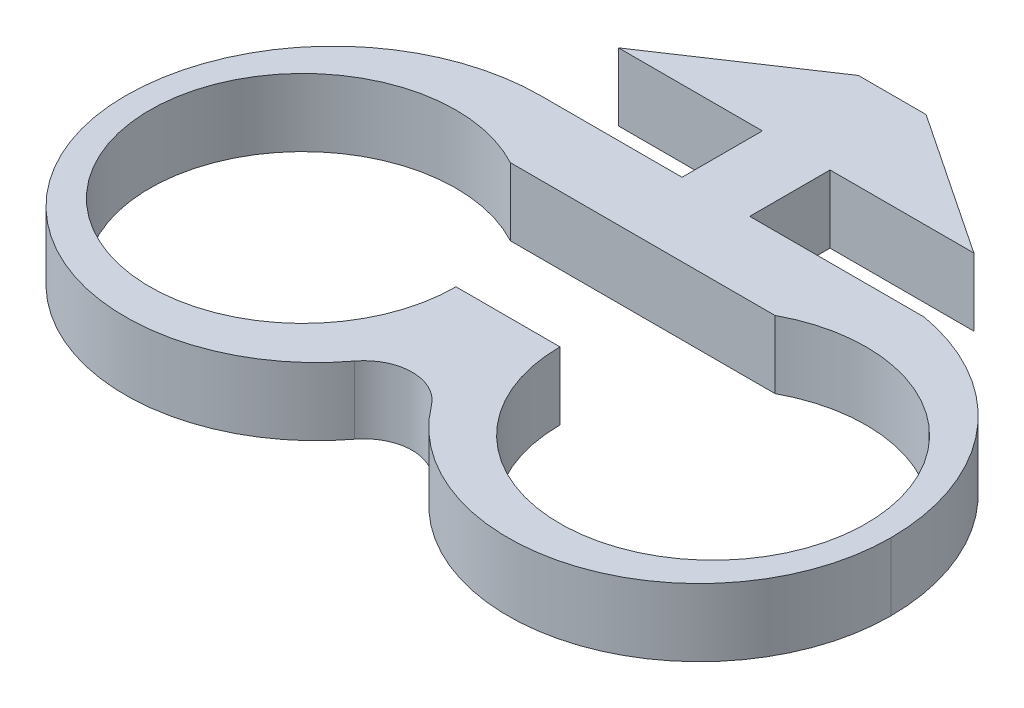
from build123d import *

# Parameters (mm, degrees)
BOSS_EXTRUDE1_DEPTH = 3.5814
BOSS_EXTRUDE2_DEPTH = 3.5814
SKETCH4_R           = 8.1
CUT_EXTRUDE2_DEPTH  = 4.5814
CUT_EXTRUDE4_REACH  = 5.581
CUT_EXTRUDE5_REACH  = 5.581


with BuildPart() as part:
    # Sketch1 → Boss-Extrude1 (new body)
    with BuildSketch(Plane(origin=(0, 0, 0), x_dir=(1, 0, 0), z_dir=(0, 1, 0))):
        Polygon((-20.25, -13.1232), (20.25, -13.1232), (20.25, -2.125), (1.7907, -2.125), (1.7907, 2.125), (9.398, 2.125), (1.7907, 7.205), (-1.7907, 7.205), (-9.398, 2.125), (-1.7907, 2.125), (-1.7907, -2.125), (-20.25, -2.125), align=None)
    extrude(amount=BOSS_EXTRUDE1_DEPTH)

    # Sketch3 → Boss-Extrude2 (add)
    with BuildSketch(Plane(origin=(0, 3.5814, 0), x_dir=(1, 0, 0), z_dir=(0, 1, 0))):
        Polygon((-20.25, -2.125), (-20.25, -13.1232), (20.25, -13.1232), (20.25, -2.125), (1.7907, -2.125), (1.7907, 2.125), (9.398, 2.125), (1.7907, 7.205), (-1.7907, 7.205), (-9.398, 2.125), (-1.7907, 2.125), (-1.7907, -2.125), align=None)
        with BuildLine():
            Line((20.25, -13.1232), (-20.25, -13.1232))
            ThreePointArc((-20.25, -13.1232), (-13.331227209, -22.72714357), (-2.030596131, -19.205654357))
            ThreePointArc((-2.030596131, -19.205654357), (0, -18.191524388), (2.030596131, -19.205654357))
            ThreePointArc((2.030596131, -19.205654357), (13.331227209, -22.72714357), (20.25, -13.1232))
        make_face()
    extrude(amount=-BOSS_EXTRUDE2_DEPTH)

    # Sketch4 → Cut-Extrude2 (cut, through all)
    with BuildSketch(Plane(origin=(0, 3.5814, 0), x_dir=(1, 0, 0), z_dir=(0, 1, 0))):
        with Locations((-10.85, -13.1232)):
            Circle(SKETCH4_R)
        with Locations((10.85, -13.1232)):
            Circle(SKETCH4_R)
    extrude(amount=-CUT_EXTRUDE2_DEPTH, mode=Mode.SUBTRACT)

    # Sketch5 → Cut-Extrude4 (cut, up to next)
    with BuildSketch(Plane(origin=(0, 3.5814, 0), x_dir=(1, 0, 0), z_dir=(0, 1, 0)), mode=Mode.PRIVATE) as cut_extrude4_sk1:
        with BuildLine():
            Line((7, -5.996665078), (-7, -5.996665078))
            ThreePointArc((-7, -5.996665078), (-3.893168825, -8.974404994), (-2.75, -13.1232))
            Line((-2.75, -13.1232), (2.75, -13.1232))
            ThreePointArc((2.75, -13.1232), (3.893168825, -8.974404994), (7, -5.996665078))
        make_face()
    cut_extrude4_tool1 = extrude(cut_extrude4_sk1.sketch, amount=-CUT_EXTRUDE4_REACH, mode=Mode.PRIVATE) & part.part
    add(cut_extrude4_tool1.solids().sort_by_distance((0, 3.5814, 8.978273))[0], mode=Mode.SUBTRACT)

    # Sketch6 → Cut-Extrude5 (cut, up to next)
    with BuildSketch(Plane(origin=(0, 3.5814, 0), x_dir=(1, 0, 0), z_dir=(0, 1, 0)), mode=Mode.PRIVATE) as cut_extrude5_sk1:
        with BuildLine():
            Line((-9.2518, -2.125), (-20.25, -2.125))
            Line((-20.25, -2.125), (-20.25, -13.1232))
            ThreePointArc((-20.25, -13.1232), (-17.028701801, -5.346298199), (-9.2518, -2.125))
        make_face()
    cut_extrude5_tool1 = extrude(cut_extrude5_sk1.sketch, amount=-CUT_EXTRUDE5_REACH, mode=Mode.PRIVATE) & part.part
    add(cut_extrude5_tool1.solids().sort_by_distance((-17.793355, 3.5814, 4.581645))[0], mode=Mode.SUBTRACT)
    # Sketch6 → Cut-Extrude5 (cut, up to next)
    with BuildSketch(Plane(origin=(0, 3.5814, 0), x_dir=(1, 0, 0), z_dir=(0, 1, 0)), mode=Mode.PRIVATE) as cut_extrude5_sk2:
        with BuildLine():
            Line((20.25, -13.1232), (20.25, -2.125))
            Line((20.25, -2.125), (11.02035, -2.125))
            ThreePointArc((11.02035, -2.125), (17.636860555, -5.94429266), (20.25, -13.1232))
        make_face()
    cut_extrude5_tool2 = extrude(cut_extrude5_sk2.sketch, amount=-CUT_EXTRUDE5_REACH, mode=Mode.PRIVATE) & part.part
    add(cut_extrude5_tool2.solids().sort_by_distance((17.919058, 3.5814, 4.610875))[0], mode=Mode.SUBTRACT)


solid = part.part
